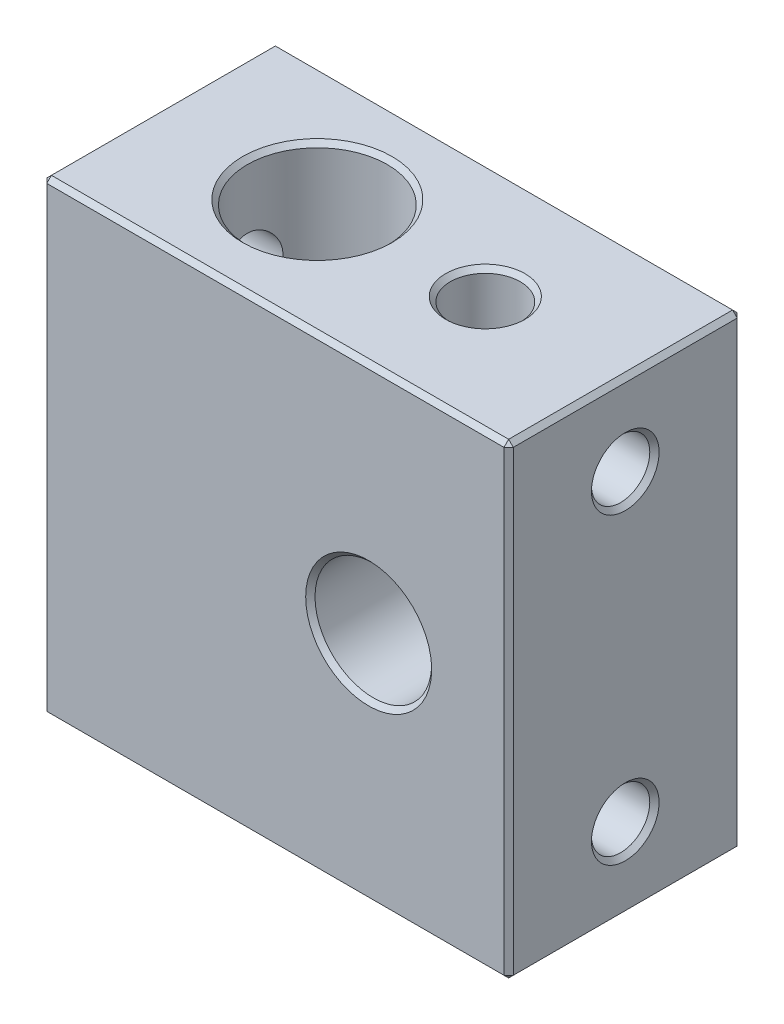
from build123d import *

# Parameters (mm, degrees)
SKETCH_1_W          = 20
SKETCH_1_H          = 20
EXTRUDE_1_DEPTH     = 10
SKETCH_2_R          = 2.5
CUT_EXTRUDE_1_DEPTH = 10
SKETCH_3_R          = 3
CUT_EXTRUDE_2_DEPTH = 20
SKETCH_4_R          = 1.25
CUT_EXTRUDE_3_DEPTH = 6.7
SKETCH_5_R          = 1.5
CUT_EXTRUDE_4_DEPTH = 6
SKETCH_6_R          = 1.5
CUT_EXTRUDE_5_DEPTH = 6
SKETCH_7_R          = 1.25
CUT_EXTRUDE_6_DEPTH = 6
CHAMFER_1_SIZE      = 0.2


with BuildPart() as part:
    # Эскиз1 → Бобышка-Вытянуть1 (new body)
    with BuildSketch(Plane.XY):
        with Locations((10, 10)):
            Rectangle(SKETCH_1_W, SKETCH_1_H)
    extrude(amount=EXTRUDE_1_DEPTH)

    # Эскиз2 → Вырез-Вытянуть1 (cut)
    with BuildSketch(Plane.XY.offset(10)):
        with Locations((14, 10)):
            Circle(SKETCH_2_R)
    extrude(amount=-CUT_EXTRUDE_1_DEPTH, mode=Mode.SUBTRACT)

    # Эскиз3 → Вырез-Вытянуть2 (cut)
    with BuildSketch(Plane.XZ):
        with Locations((6.8, 5)):
            Circle(SKETCH_3_R)
    extrude(amount=-CUT_EXTRUDE_2_DEPTH, mode=Mode.SUBTRACT)

    # Эскиз4 → Вырез-Вытянуть3 (cut)
    with BuildSketch(Plane.ZY):
        with Locations((5, 16)):
            Circle(SKETCH_4_R)
        with Locations((5, 4)):
            Circle(SKETCH_4_R)
    extrude(amount=-CUT_EXTRUDE_3_DEPTH, mode=Mode.SUBTRACT)

    # Эскиз5 → Вырез-Вытянуть4 (cut)
    with BuildSketch(Plane.XZ):
        with Locations((14, 5)):
            Circle(SKETCH_5_R)
    extrude(amount=-CUT_EXTRUDE_4_DEPTH, mode=Mode.SUBTRACT)

    # Эскиз6 → Вырез-Вытянуть5 (cut)
    with BuildSketch(Plane(origin=(0, 20, 0), x_dir=(1, 0, 0), z_dir=(0, 1, 0))):
        with Locations((14, -5)):
            Circle(SKETCH_6_R)
    extrude(amount=-CUT_EXTRUDE_5_DEPTH, mode=Mode.SUBTRACT)

    # Эскиз7 → Вырез-Вытянуть6 (cut)
    with BuildSketch(Plane(origin=(20, 0, 0), x_dir=(0, 0, -1), z_dir=(1, 0, 0))):
        with Locations((-5, 3.5)):
            Circle(SKETCH_7_R)
        with Locations((-5, 16.5)):
            Circle(SKETCH_7_R)
    extrude(amount=-CUT_EXTRUDE_6_DEPTH, mode=Mode.SUBTRACT)

    # Фаска1
    chamfer_1_edges = [part.edges().sort_by_distance(p)[0] for p in [
        (20, 10, 10),
        (10, 20, 10),
        (11.5, 10, 0),
        (11.5, 10, 10),
        (3.8, 20, 5),
        (3.8, 0, 5),
        (0, 16, 3.75),
        (0, 4, 3.75),
        (12.5, 0, 5),
        (12.5, 20, 5),
        (0, 10, 10),
        (20, 3.5, 6.25),
        (10, 20, 0),
        (20, 10, 0),
        (20, 16.5, 6.25),
        (10, 0, 0),
        (0, 10, 0),
        (10, 0, 10),
        (0, 20, 5),
        (20, 20, 5),
        (20, 0, 5),
        (0, 0, 5),
    ]]
    chamfer(chamfer_1_edges, length=CHAMFER_1_SIZE)


solid = part.part
